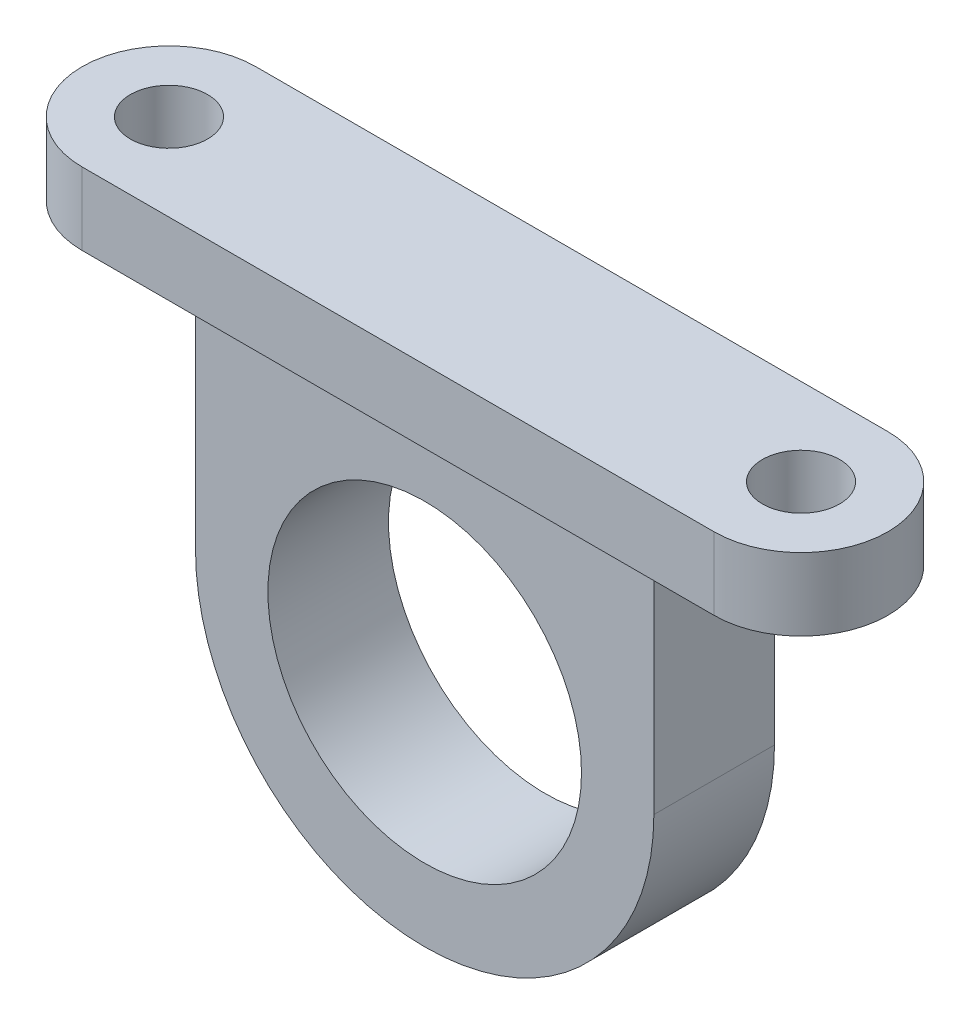
from build123d import *

# Parameters (mm, degrees)
SKETCH1_R           = 6.5
BOSS_EXTRUDE1_DEPTH = 5
SKETCH2_R           = 1.6
BOSS_EXTRUDE2_DEPTH = 3


with BuildPart() as part:
    # Sketch1 → Boss-Extrude1 (new body)
    with BuildSketch(Plane.XY):
        with BuildLine():
            Line((-9.5, 0), (-9.5, 9.5))
            Line((-9.5, 9.5), (9.5, 9.5))
            Line((9.5, 9.5), (9.5, 0))
            ThreePointArc((9.5, 0), (0, -9.5), (-9.5, 0))
        make_face()
        Circle(SKETCH1_R, mode=Mode.SUBTRACT)
    extrude(amount=BOSS_EXTRUDE1_DEPTH)

    # Sketch2 → Boss-Extrude2 (add)
    with BuildSketch(Plane(origin=(0, 9.5, 0), x_dir=(1, 0, 0), z_dir=(0, 1, 0))):
        with BuildLine():
            Line((13.1, 1.1), (-13.1, 1.1))
            ThreePointArc((-13.1, 1.1), (-16.7, -2.5), (-13.1, -6.1))
            Line((-13.1, -6.1), (13.1, -6.1))
            ThreePointArc((13.1, -6.1), (16.7, -2.5), (13.1, 1.1))
        make_face()
        with Locations((-13.1, -2.5)):
            Circle(SKETCH2_R, mode=Mode.SUBTRACT)
        with Locations((13.1, -2.5)):
            Circle(SKETCH2_R, mode=Mode.SUBTRACT)
    extrude(amount=BOSS_EXTRUDE2_DEPTH)


solid = part.part
